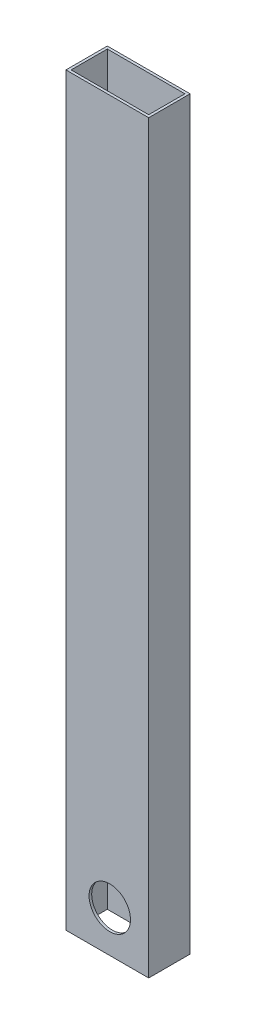
from build123d import *

# Parameters (mm, degrees)
SKETCH1_W           = 50.8
SKETCH1_H           = 25.4
SKETCH1_W_2         = 47.625
SKETCH1_H_2         = 22.225
BOSS_EXTRUDE1_DEPTH = 457.2
SKETCH2_R           = 12.7
CUT_EXTRUDE1_DEPTH  = 457.2


with BuildPart() as part:
    # Sketch1 → Boss-Extrude1 (new body)
    with BuildSketch(Plane(origin=(0, 0, 0), x_dir=(1, 0, 0), z_dir=(0, 1, 0))):
        Rectangle(SKETCH1_W, SKETCH1_H)
        Rectangle(SKETCH1_W_2, SKETCH1_H_2, mode=Mode.SUBTRACT)
    extrude(amount=BOSS_EXTRUDE1_DEPTH)

    # Sketch2 → Cut-Extrude1 (cut)
    with BuildSketch(Plane(origin=(0, 0, -12.7), x_dir=(-1, 0, 0), z_dir=(0, 0, -1))):
        with Locations((-1.524, 25.4)):
            Circle(SKETCH2_R)
    extrude(amount=-CUT_EXTRUDE1_DEPTH, mode=Mode.SUBTRACT)


solid = part.part
